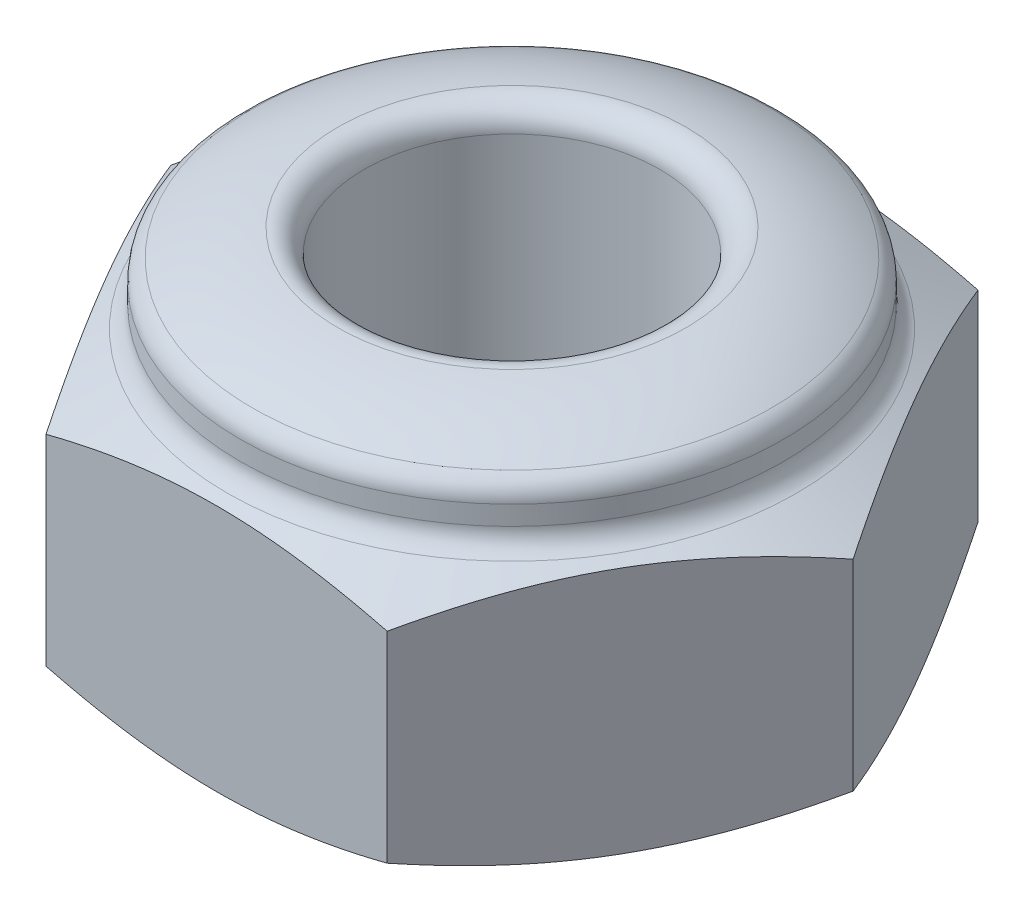
from build123d import *

# Parameters (mm, degrees)
SKETCH_1_R      = 1.25
EXTRUDE_1_DEPTH = 1.15
FILLET_1_R      = 0.2


with BuildPart() as part:
    # 草图1 → 凸台-拉伸1 (new body, symmetric)
    with BuildSketch(Plane(origin=(0, 0, 0), x_dir=(1, 0, 0), z_dir=(0, 1, 0))):
        Polygon((2.886751346, 0), (1.443375673, 2.5), (-1.443375673, 2.5), (-2.886751346, 0), (-1.443375673, -2.5), (1.443375673, -2.5), align=None)
        Circle(SKETCH_1_R, mode=Mode.SUBTRACT)
    extrude(amount=EXTRUDE_1_DEPTH, both=True)

    # 草图2 → 切除-旋转1 (revolve, cut)
    with BuildSketch(Plane.XY):
        Polygon((-2.886751346, 0.85), (-2.3, 1.15), (-2.886751346, 1.15), align=None)
    cut_revolve_1 = revolve(axis=Axis((0, 1.15, 0), (0, -1, 0)), mode=Mode.SUBTRACT)

    # 镜向1: 切除-旋转1 across plane
    add(cut_revolve_1.mirror(Plane.ZX), mode=Mode.SUBTRACT)

    # 草图3 → 旋转1 (revolve)
    with BuildSketch(Plane(origin=(0, 0, 0), x_dir=(0, 0, -1), z_dir=(1, 0, 0))):
        with BuildLine():
            Line((-2.3, 1.15), (-2.3, 1.55))
            ThreePointArc((-2.3, 1.55), (-1.796008242, 1.773528846), (-1.25, 1.85))
            Line((-1.25, 1.85), (-1.25, 1.15))
            Line((-1.25, 1.15), (-2.3, 1.15))
        make_face()
    revolve(axis=Axis((0, 1.15, 0), (0, -1, 0)))

    # 圆角1
    fillet_1_edges = [part.edges().sort_by_distance(p)[0] for p in [
        (1.626345597, 1.15, -1.626345597),
        (0, 1.55, -2.3),
        (0, 1.85, -1.25),
    ]]
    fillet(fillet_1_edges, radius=FILLET_1_R)


solid = part.part
